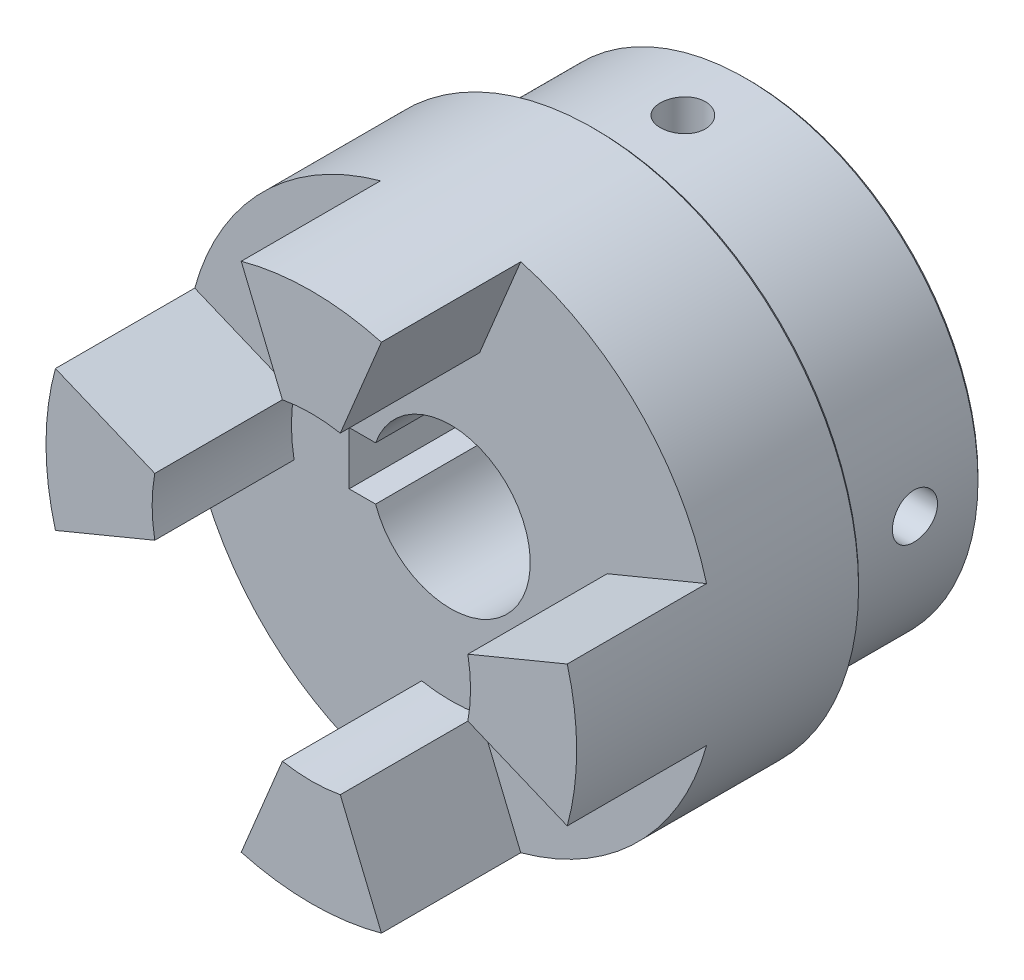
from build123d import *

# Parameters (mm, degrees)
BOSS_EXTRUDE1_DEPTH = 21
CIRPATTERN1_COUNT   = 4
CUT_EXTRUDE2_DEPTH  = 46
SKETCH12_W          = 3.4
SKETCH12_H          = 35
CIRPATTERN2_COUNT   = 2
CIRPATTERN2_ANGLE   = 90


with BuildPart() as part:
    # Sketch3 → Revolve2 (revolve)
    with BuildSketch(Plane(origin=(0, 0, 0), x_dir=(0, 0, -1), z_dir=(1, 0, 0))):
        Polygon((22.5, 0), (22.5, 34.5), (22, 35), (-0.5, 35), (-0.5, 39.5), (-1, 40), (-22.5, 40), (-22.5, 0), align=None)
    revolve(axis=Axis((0, 0, 22.5), (0, 0, -1)))

    # Sketch5 → Boss-Extrude1 (add)
    with BuildSketch(Plane.XY.offset(22.5)):
        with BuildLine():
            Line((-4.365, 23.59972), (-10.56935, 38.578347))
            ThreePointArc((-10.56935, 38.578347), (0, 40), (10.56935, 38.578347))
            Line((10.56935, 38.578347), (4.365, 23.59972))
            ThreePointArc((4.365, 23.59972), (0, 24), (-4.365, 23.59972))
        make_face()
    boss_extrude1 = extrude(amount=BOSS_EXTRUDE1_DEPTH)

    # CirPattern1: Boss-Extrude1 ×4 about axis
    cirpattern1_axis = Axis((0, 0, 0), (0, 0, 1))
    for i in range(1, CIRPATTERN1_COUNT):
        add(boss_extrude1.rotate(cirpattern1_axis, i * 360 / CIRPATTERN1_COUNT))

    # Sketch6 → Cut-Extrude2 (cut, through all)
    with BuildSketch(Plane.XY.offset(22.5)):
        with BuildLine():
            ThreePointArc((12, 0), (2.029224, 11.827183), (-11.313708, 4))
            Line((-11.313708, 4), (-8.7, 4))
            Line((-8.7, 4), (-8.7, -4))
            Line((-8.7, -4), (-11.313708, -4))
            ThreePointArc((-11.313708, -4), (2.029224, -11.827183), (12, 0))
        make_face()
        with BuildLine():
            Line((-8.7, 4), (-11.313708, 4))
            ThreePointArc((-11.313708, 4), (-12, 0), (-11.313708, -4))
            Line((-11.313708, -4), (-8.7, -4))
            Line((-8.7, -4), (-8.7, 4))
        make_face()
        with BuildLine():
            Line((-11.313708, 4), (-15.3, 4))
            Line((-15.3, 4), (-15.3, -4))
            Line((-15.3, -4), (-11.313708, -4))
            ThreePointArc((-11.313708, -4), (-12, 0), (-11.313708, 4))
        make_face()
    extrude(amount=-CUT_EXTRUDE2_DEPTH, mode=Mode.SUBTRACT)

    # Sketch12 → Tap Drill for M8x1.25 Tap2 (revolve, cut)
    with BuildSketch(Plane(origin=(0, 0, -12.5), x_dir=(0, 0, 1), z_dir=(0, 1, 0))):
        with Locations((1.7, 17.5)):
            Rectangle(SKETCH12_W, SKETCH12_H)
    tap_drill_for_m8x1_25_tap2 = revolve(axis=Axis((-6.35, 0, -12.5), (1, 0, 0)), mode=Mode.SUBTRACT)

    # CirPattern2: Tap Drill for M8x1.25 Tap2 ×2 about axis
    cirpattern2_axis = Axis((0, 0, 22.5), (0, 0, 1))
    for i in range(1, CIRPATTERN2_COUNT):
        add(tap_drill_for_m8x1_25_tap2.rotate(cirpattern2_axis, i * CIRPATTERN2_ANGLE / (CIRPATTERN2_COUNT - 1)), mode=Mode.SUBTRACT)


solid = part.part
